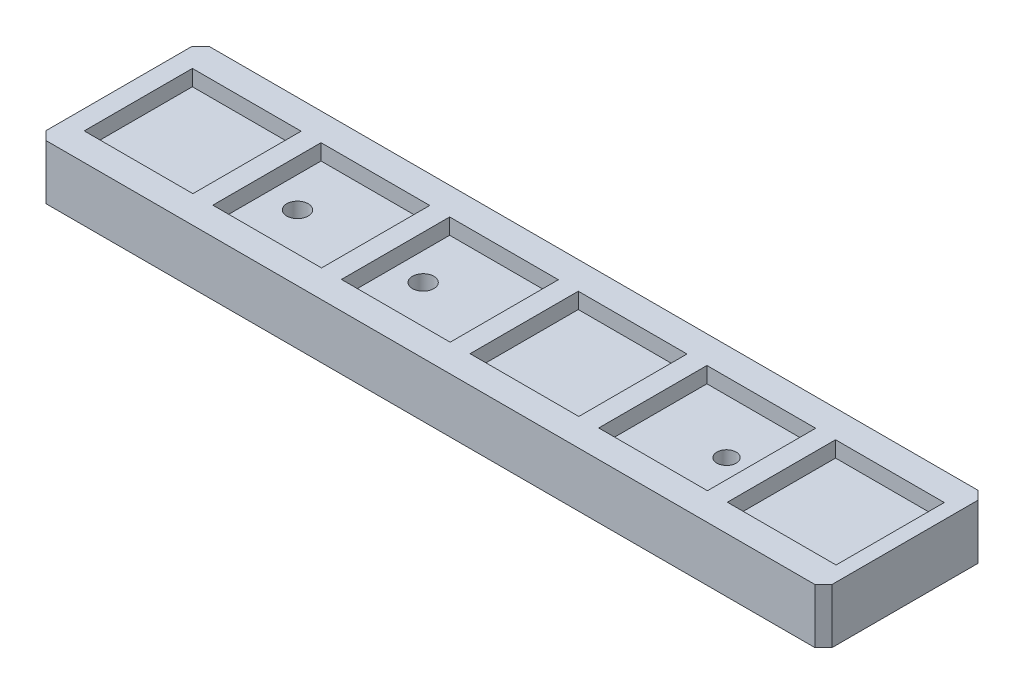
from build123d import *

# Parameters (mm, degrees)
ESBO_O1_W                = 183.2
ESBO_O1_H                = 38.02
RESSALTO_EXTRUS_O1_DEPTH = 12.75
ESBO_O3_W                = 25.34
ESBO_O3_H                = 25.22
CORTE_EXTRUS_O1_DEPTH    = 3.7
CHANFRO1_SIZE            = 2
ESBO_O4_R                = 2.25
ESBO_O4_R_2              = 2.5
CORTE_EXTRUS_O2_DEPTH    = 10100


with BuildPart() as part:
    # Esboço1 → Ressalto-extrusão1 (new body)
    with BuildSketch(Plane(origin=(0, 0, 0), x_dir=(1, 0, 0), z_dir=(0, 1, 0))):
        with Locations((-91.6, 19.01)):
            Rectangle(ESBO_O1_W, ESBO_O1_H)
    extrude(amount=RESSALTO_EXTRUS_O1_DEPTH)

    # Esboço3 → Corte-extrusão1 (cut)
    with BuildSketch(Plane(origin=(0, 12.75, 0), x_dir=(1, 0, 0), z_dir=(0, 1, 0))):
        with Locations((-166.03, 19.01)):
            Rectangle(ESBO_O3_W, ESBO_O3_H)
        with Locations((-136.05, 19.01)):
            Rectangle(ESBO_O3_W, ESBO_O3_H)
        with Locations((-106.07, 19.01)):
            Rectangle(ESBO_O3_W, ESBO_O3_H)
        with Locations((-76.09, 19.01)):
            Rectangle(ESBO_O3_W, ESBO_O3_H)
        with Locations((-46.11, 19.01)):
            Rectangle(ESBO_O3_W, ESBO_O3_H)
        with Locations((-16.13, 19.01)):
            Rectangle(ESBO_O3_W, ESBO_O3_H)
    extrude(amount=-CORTE_EXTRUS_O1_DEPTH, mode=Mode.SUBTRACT)

    # Chanfro1
    chanfro1_edges = [part.edges().sort_by_distance(p)[0] for p in [
        (0, 6.375, 0),
        (-183.2, 6.375, 0),
        (-183.2, 6.375, -38.02),
        (0, 6.375, -38.02),
    ]]
    chamfer(chanfro1_edges, length=CHANFRO1_SIZE)

    # Esboço4 → Corte-extrusão2 (cut)
    with BuildSketch(Plane(origin=(0, 12.75, 0), x_dir=(1, 0, 0), z_dir=(0, 1, 0))):
        with Locations((-41.6, 19.01)):
            Circle(ESBO_O4_R)
        with Locations((-141.6, 19.01)):
            Circle(ESBO_O4_R_2)
        with Locations((-112.310678119, 19.01)):
            Circle(ESBO_O4_R_2)
    extrude(amount=-CORTE_EXTRUS_O2_DEPTH, mode=Mode.SUBTRACT)


solid = part.part
